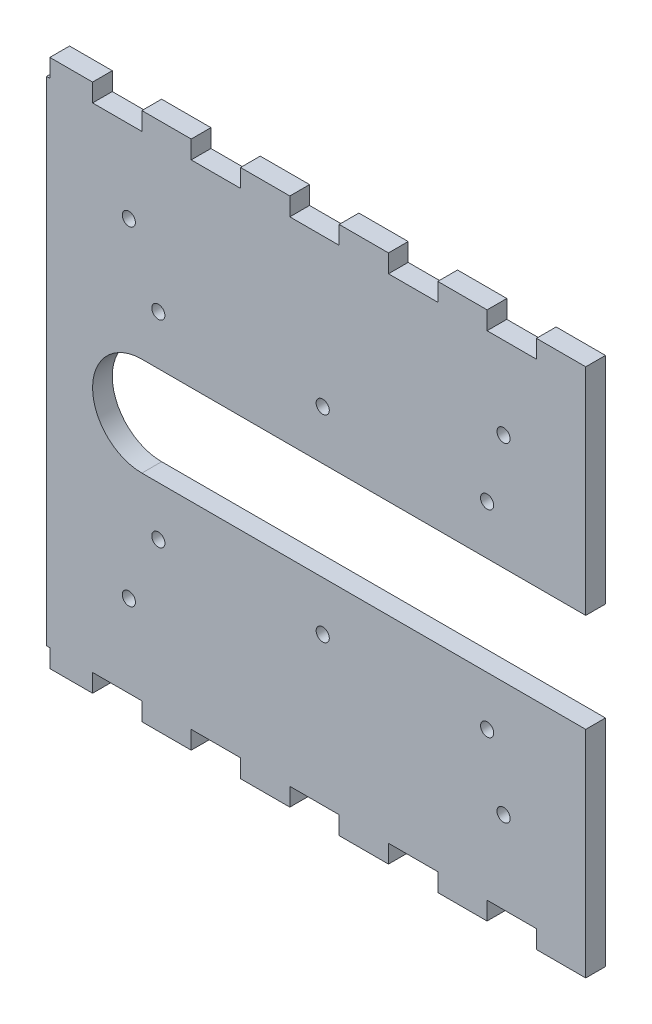
from build123d import *

# Parameters (mm, degrees)
MODEL_R             = 2
BOSS_EXTRUDE1_DEPTH = 6
SKETCH2_W           = 6
SKETCH2_H           = 150
BOSS_EXTRUDE2_DEPTH = 1


with BuildPart() as part:
    # Model → Boss-Extrude1 (new body)
    with BuildSketch(Plane.XY):
        with BuildLine():
            Line((31.391248016, 13.680569099), (46.391248016, 13.680569099))
            Line((46.391248016, 13.680569099), (46.391248016, 8.180569099))
            Line((46.391248016, 8.180569099), (61.391248016, 8.180569099))
            Line((61.391248016, 8.180569099), (61.391248016, 13.680569099))
            Line((61.391248016, 13.680569099), (76.391248016, 13.680569099))
            Line((76.391248016, 13.680569099), (76.391248016, 8.180569099))
            Line((76.391248016, 8.180569099), (91.391248016, 8.180569099))
            Line((91.391248016, 8.180569099), (91.391248016, 13.680569099))
            Line((91.391248016, 13.680569099), (106.391248016, 13.680569099))
            Line((106.391248016, 13.680569099), (106.391248016, 8.180569099))
            Line((106.391248016, 8.180569099), (121.391248016, 8.180569099))
            Line((121.391248016, 8.180569099), (121.391248016, 13.680569099))
            Line((121.391248016, 13.680569099), (136.391248016, 13.680569099))
            Line((136.391248016, 13.680569099), (136.391248016, 8.180569099))
            Line((136.391248016, 8.180569099), (151.391248016, 8.180569099))
            Line((151.391248016, 8.180569099), (151.391248016, 13.680569099))
            Line((151.391248016, 13.680569099), (166.391248016, 13.680569099))
            Line((166.391248016, 13.680569099), (166.391248016, 8.180569099))
            Line((166.391248016, 8.180569099), (181.391248016, 8.180569099))
            Line((181.391248016, 8.180569099), (181.391248016, 73.680569099))
            Line((181.391248016, 73.680569099), (46.391248016, 73.680569099))
            ThreePointArc((46.391248016, 73.680569099), (31.391248016, 88.680569099), (46.391248016, 103.680569099))
            Line((46.391248016, 103.680569099), (181.391248016, 103.680569099))
            Line((181.391248016, 103.680569099), (181.391248016, 169.180569099))
            Line((181.391248016, 169.180569099), (166.391248016, 169.180569099))
            Line((166.391248016, 169.180569099), (166.391248016, 163.680569099))
            Line((166.391248016, 163.680569099), (151.391248016, 163.680569099))
            Line((151.391248016, 163.680569099), (151.391248016, 169.180569099))
            Line((151.391248016, 169.180569099), (136.391248016, 169.180569099))
            Line((136.391248016, 169.180569099), (136.391248016, 163.680569099))
            Line((136.391248016, 163.680569099), (121.391248016, 163.680569099))
            Line((121.391248016, 163.680569099), (121.391248016, 169.180569099))
            Line((121.391248016, 169.180569099), (106.391248016, 169.180569099))
            Line((106.391248016, 169.180569099), (106.391248016, 163.680569099))
            Line((106.391248016, 163.680569099), (91.391248016, 163.680569099))
            Line((91.391248016, 163.680569099), (91.391248016, 169.180569099))
            Line((91.391248016, 169.180569099), (76.391248016, 169.180569099))
            Line((76.391248016, 169.180569099), (76.391248016, 163.680569099))
            Line((76.391248016, 163.680569099), (61.391248016, 163.680569099))
            Line((61.391248016, 163.680569099), (61.391248016, 169.180569099))
            Line((61.391248016, 169.180569099), (46.391248016, 169.180569099))
            Line((46.391248016, 169.180569099), (46.391248016, 163.680569099))
            Line((46.391248016, 163.680569099), (31.391248016, 163.680569099))
            Line((31.391248016, 163.680569099), (31.391248016, 169.180569099))
            Line((31.391248016, 169.180569099), (18.391248016, 169.180569099))
            Line((18.391248016, 169.180569099), (18.391248016, 8.180569099))
            Line((18.391248016, 8.180569099), (31.391248016, 8.180569099))
            Line((31.391248016, 8.180569099), (31.391248016, 13.680569099))
        make_face()
        with Locations((51.391248016, 58.680569099)):
            Circle(MODEL_R, mode=Mode.SUBTRACT)
        with Locations((101.391248016, 58.680569099)):
            Circle(MODEL_R, mode=Mode.SUBTRACT)
        with Locations((151.391248016, 58.680569099)):
            Circle(MODEL_R, mode=Mode.SUBTRACT)
        with Locations((42.423326125, 38.680569099)):
            Circle(MODEL_R, mode=Mode.SUBTRACT)
        with Locations((156.391248016, 38.680569099)):
            Circle(MODEL_R, mode=Mode.SUBTRACT)
        with Locations((51.391248016, 118.680569099)):
            Circle(MODEL_R, mode=Mode.SUBTRACT)
        with Locations((101.391248016, 118.680569099)):
            Circle(MODEL_R, mode=Mode.SUBTRACT)
        with Locations((151.391248016, 118.680569099)):
            Circle(MODEL_R, mode=Mode.SUBTRACT)
        with Locations((42.423326125, 138.680569099)):
            Circle(MODEL_R, mode=Mode.SUBTRACT)
        with Locations((156.391248016, 138.680569099)):
            Circle(MODEL_R, mode=Mode.SUBTRACT)
    extrude(amount=BOSS_EXTRUDE1_DEPTH)

    # Sketch2 → Boss-Extrude2 (add)
    with BuildSketch(Plane.ZY.offset(-18.391248016)):
        with Locations((3, 88.680569099)):
            Rectangle(SKETCH2_W, SKETCH2_H)
    extrude(amount=BOSS_EXTRUDE2_DEPTH)


solid = part.part
